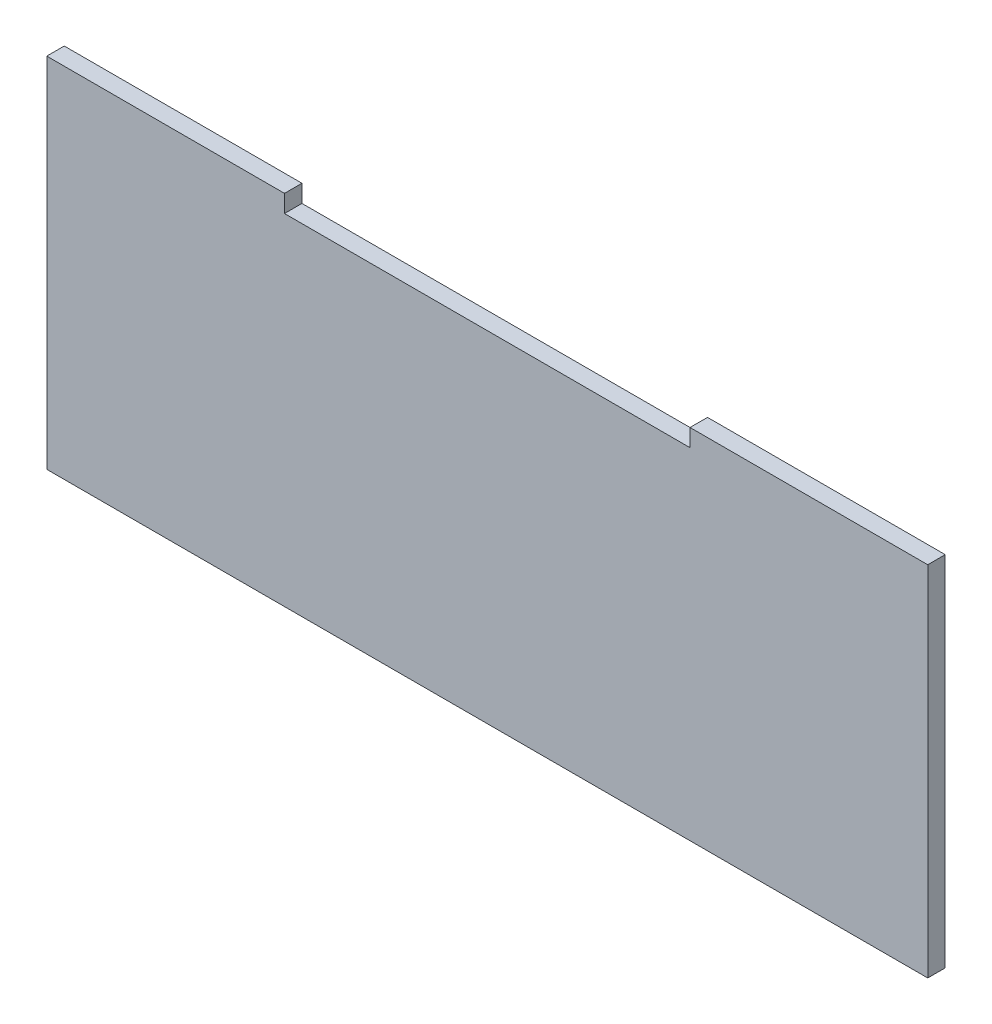
from build123d import *

# Parameters (mm, degrees)
BOSS_EXTRUDE1_DEPTH = 3.175


with BuildPart() as part:
    # Sketch1 → Boss-Extrude1 (new body)
    with BuildSketch(Plane.XY):
        Polygon((0, 0), (80, 0), (80, 65), (36.825, 65), (36.825, 61.825), (-36.825, 61.825), (-36.825, 65), (-80, 65), (-80, 0), align=None)
    extrude(amount=BOSS_EXTRUDE1_DEPTH)


solid = part.part
